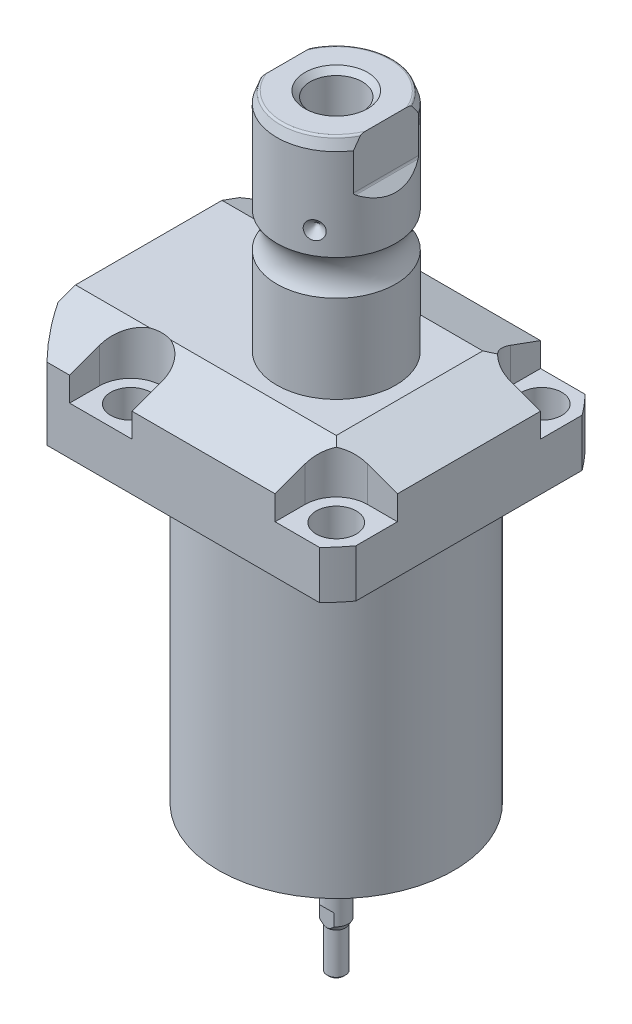
from build123d import *

# Parameters (mm, degrees)
SKETCH1_W                = 70.866
SKETCH1_H                = 85.496
EXTRUDE1_DEPTH           = 104.4448
SKETCH2_OUTSIDE_W        = 117.986
SKETCH2_OUTSIDE_H        = 103.356
SKETCH2_OUTSIDE_R        = 50.8
CUT_EXTRUDE1_DEPTH       = 105.4448
SKETCH3_W                = 45.1992
SKETCH3_H                = 79.4258
FILLET1_R                = 0.381
CUT_EXTRUDE2_DEPTH       = 12.243
CUT_EXTRUDE9_START       = -51.063
CUT_EXTRUDE9_DEPTH       = 87.496
CUT_EXTRUDE7_DEPTH       = 36.433
CUT_EXTRUDE7_DEPTH_BACK  = 36.433
SKETCH10_R               = 1.1811
SKETCH17_W               = 5.3594
SKETCH17_H               = 12.776
HOLE1_AT_2_COUNT         = 2
HOLE1_AT_2_PITCH         = 54.864
HOLE1_AT_3_COUNT         = 2
HOLE1_AT_3_PITCH         = 77.589412886
HOLE1_AT_4_COUNT         = 2
HOLE1_AT_4_PITCH         = 54.864
CHAMFER1_SIZE            = 0.635
FILLET2_R                = 0.635
CIRPATTERN1_COUNT        = 3
CUT_EXTRUDE10_DEPTH      = 36.433
CUT_EXTRUDE10_DEPTH_BACK = 36.433
CHAMFER2_SIZE            = 1.4351
SKETCH30_R               = 1.27
CUT_EXTRUDE11_DEPTH      = 7.62
SKETCH31_W               = 2.7051
SKETCH31_H               = 1.3208
CUT_EXTRUDE12_DEPTH      = 3.175


with BuildPart() as part:
    # Sketch1 → Extrude1 (new body)
    with BuildSketch(Plane(origin=(0, 0, 0), x_dir=(0, 0, 1), z_dir=(0, -1, 0))):
        with Locations((0, 7.315)):
            Rectangle(SKETCH1_W, SKETCH1_H)
    extrude(amount=-EXTRUDE1_DEPTH)

    # Sketch2 outside → Cut-Extrude1 (cut, through all)
    with BuildSketch(Plane.XZ):
        with Locations((-7.315, 0)):
            Rectangle(SKETCH2_OUTSIDE_W, SKETCH2_OUTSIDE_H)
        with Locations((-5.4102, 0)):
            Circle(SKETCH2_OUTSIDE_R, mode=Mode.SUBTRACT)
    extrude(amount=-CUT_EXTRUDE1_DEPTH, mode=Mode.SUBTRACT)

    # Sketch3 → Cut-Revolve1 (revolve, cut)
    with BuildSketch(Plane(origin=(0, 0, 0), x_dir=(0, 0, -1), z_dir=(1, 0, 0))):
        with Locations((53.9941, 39.7129)):
            Rectangle(SKETCH3_W, SKETCH3_H)
    revolve(axis=Axis((0, -93.345, 0), (0, 1, 0)), mode=Mode.SUBTRACT)

    # Fillet1
    fillet1_edges = [part.edges().sort_by_distance(p)[0] for p in [
        (0, 79.4258, 31.3945),
    ]]
    fillet(fillet1_edges, radius=FILLET1_R)

    # Sketch4 → Cut-Extrude2 (cut)
    with BuildSketch(Plane(origin=(0, 104.4448, 0), x_dir=(-1, 0, 0), z_dir=(0, 1, 0))):
        with BuildLine():
            Line((-19.1008, -35.433), (-19.1008, -27.432))
            ThreePointArc((-19.1008, -27.432), (-21.540951985, -21.540951985), (-27.432, -19.1008))
            Line((-27.432, -19.1008), (-35.433, -19.1008))
            Line((-35.433, -19.1008), (-35.433, -35.433))
            Line((-35.433, -35.433), (-19.1008, -35.433))
        make_face()
        with BuildLine():
            Line((35.7632, -35.433), (19.1008, -35.433))
            Line((19.1008, -35.433), (19.1008, -27.432))
            ThreePointArc((19.1008, -27.432), (27.432, -19.1008), (35.7632, -27.432))
            Line((35.7632, -27.432), (35.7632, -35.433))
        make_face()
        with BuildLine():
            Line((19.1008, 35.433), (19.1008, 27.432))
            ThreePointArc((19.1008, 27.432), (27.432, 19.1008), (35.7632, 27.432))
            Line((35.7632, 27.432), (35.7632, 35.433))
            Line((35.7632, 35.433), (19.1008, 35.433))
        make_face()
        with BuildLine():
            Line((-27.432, 19.1008), (-35.433, 19.1008))
            Line((-35.433, 19.1008), (-35.433, 35.433))
            Line((-35.433, 35.433), (-19.1008, 35.433))
            Line((-19.1008, 35.433), (-19.1008, 27.432))
            ThreePointArc((-19.1008, 27.432), (-21.540951985, 21.540951985), (-27.432, 19.1008))
        make_face()
    extrude(amount=-CUT_EXTRUDE2_DEPTH, mode=Mode.SUBTRACT)

    # Sketch5 → Cut-Extrude9 (cut)
    with BuildSketch(Plane(origin=(0, 0, 0), x_dir=(0, 0, -1), z_dir=(1, 0, 0)).offset(CUT_EXTRUDE9_START)):
        Polygon((-19.558, 104.4448), (-35.433, 98.666772531), (-35.433, 104.4448), align=None)
    cut_extrude9 = extrude(amount=CUT_EXTRUDE9_DEPTH, mode=Mode.SUBTRACT)

    # Mirror1: Cut-Extrude9 across plane
    add(cut_extrude9.mirror(Plane.XY), mode=Mode.SUBTRACT)

    # Sketch9 → Cut-Extrude7 (cut, two sides)
    with BuildSketch(Plane.XY) as cut_extrude7_sk:
        Polygon((19.558, 104.4448), (35.433, 98.666772531), (35.433, 104.4448), align=None)
    extrude(amount=CUT_EXTRUDE7_DEPTH, mode=Mode.SUBTRACT)
    extrude(cut_extrude7_sk.sketch, amount=-CUT_EXTRUDE7_DEPTH_BACK, mode=Mode.SUBTRACT)

    # Sketch20 → Cut-Revolve4 (revolve, cut)
    with BuildSketch(Plane(origin=(-35.0774, 88.9, -18.1102), x_dir=(0, 1, 0), z_dir=(1, 0, 0)), mode=Mode.PRIVATE) as cut_revolve4_sk:
        Polygon((-9.4742, 38.3413), (-8.0264, 38.3413), (-8.0264, 35.8902), (-7.0104, 35.8902), (-7.0104, 33.8836), (3.9624, 33.8836), (3.9624, 32.639), (-9.4742, 32.639), align=None)
    cut_revolve4 = revolve(cut_revolve4_sk.sketch.rotate(Axis((-35.0774, 81.620304954, 14.5288), (0, 1, 0)), 180), axis=Axis((-35.0774, 81.620304954, 14.5288), (0, 1, 0)), mode=Mode.SUBTRACT)  # turned: the seam where the file's is

    # Mirror10: Cut-Revolve4 across plane
    add(cut_revolve4.mirror(Plane.XY), mode=Mode.SUBTRACT)

    # Sketch15 → Revolve3 (revolve)
    with BuildSketch(Plane(origin=(0, 0, 0), x_dir=(0, 0, -1), z_dir=(1, 0, 0)), mode=Mode.PRIVATE) as revolve3_sk:
        with BuildLine():
            Line((0, 104.4448), (15.875, 104.4448))
            Line((15.875, 104.4448), (15.875, 127.82970643))
            ThreePointArc((15.875, 127.82970643), (14.3256, 132.5368), (15.875, 137.24389357))
            Line((15.875, 137.24389357), (15.875, 161.72179416))
            Line((15.875, 161.72179416), (14.81184082, 164.6428))
            Line((14.81184082, 164.6428), (0, 164.6428))
            Line((0, 164.6428), (0, 104.4448))
        make_face()
    revolve(revolve3_sk.sketch.rotate(Axis((0, 250.290824608, 0), (0, -1, 0)), 180), axis=Axis((0, 250.290824608, 0), (0, -1, 0)))  # turned: the seam where the file's is

    # Sketch17 → Hole1 (revolve, cut)
    with BuildSketch(Plane(origin=(27.432, 92.2018, -27.432), x_dir=(0, 0, 1), z_dir=(1, 0, 0))):
        with Locations((2.6797, 6.388)):
            Rectangle(SKETCH17_W, SKETCH17_H)
    hole1 = revolve(axis=Axis((27.432, -17.7982, -27.432), (0, 1, 0)), mode=Mode.SUBTRACT)

    # Hole1 at 2: Hole1 ×2
    with Locations(*[(0, 0, i * HOLE1_AT_2_PITCH) for i in range(1, HOLE1_AT_2_COUNT)]):
        add(hole1, mode=Mode.SUBTRACT)

    # Hole1 at 3: Hole1 ×2
    with Locations(*[Vector(-0.707106781, 0, 0.707106781) * (i * HOLE1_AT_3_PITCH) for i in range(1, HOLE1_AT_3_COUNT)]):
        add(hole1, mode=Mode.SUBTRACT)

    # Hole1 at 4: Hole1 ×2
    with Locations(*[(-i * HOLE1_AT_4_PITCH, 0, 0) for i in range(1, HOLE1_AT_4_COUNT)]):
        add(hole1, mode=Mode.SUBTRACT)

    # Chamfer1
    chamfer1_edges = [part.edges().sort_by_distance(p)[0] for p in [
        (-35.0774, 81.8896, 15.7734),
        (-35.0774, 81.8896, -15.7734),
    ]]
    chamfer(chamfer1_edges, length=CHAMFER1_SIZE)

    # Sketch21 → Cut-Revolve5 (revolve, cut)
    with BuildSketch(Plane.XZ.offset(-91.9226)):
        Polygon((-50.063, -1.9304), (-49.809, -1.9304), (-49.809, -6.7564), (-47.2563, -7.440393904), (-46.695693904, -8.001), (-30.759, -8.001), (-30.759, -12.9794), (-50.063, -12.9794), align=None)
    cut_revolve5 = revolve(axis=Axis((-57.549532301, 91.9226, -12.9794), (1, 0, 0)), mode=Mode.SUBTRACT)

    # Mirror13: Cut-Revolve5 across plane
    add(cut_revolve5.mirror(Plane.XY), mode=Mode.SUBTRACT)

    # Fillet2
    fillet2_edges = [part.edges().sort_by_distance(p)[0] for p in [
        (0, 164.6428, -14.81184082),
    ]]
    fillet(fillet2_edges, radius=FILLET2_R)

    # Sketch26 → Cut-Revolve7 (revolve, cut)
    with BuildSketch(Plane.XY, mode=Mode.PRIVATE) as cut_revolve7_sk:
        Polygon((-15.875, 145.6178), (-13.462, 143.2048), (-15.875, 143.2048), align=None)
    cut_revolve7 = revolve(cut_revolve7_sk.sketch.rotate(Axis((-39.772000707, 143.2048, 0), (1, 0, 0)), 90), axis=Axis((-39.772000707, 143.2048, 0), (1, 0, 0)), mode=Mode.SUBTRACT)  # turned: the seam where the file's is

    # CirPattern1: Cut-Revolve7 ×3 about axis
    cirpattern1_axis = Axis((0, 250.290824608, 0), (0, 1, 0))
    for i in range(1, CIRPATTERN1_COUNT):
        add(cut_revolve7.rotate(cirpattern1_axis, i * 360 / CIRPATTERN1_COUNT), mode=Mode.SUBTRACT)

    # Sketch27 → Hole2 (revolve, cut)
    with BuildSketch(Plane(origin=(0, 164.6428, 0), x_dir=(0, 0, 1), z_dir=(1, 0, 0))):
        Polygon((0, 0), (0, 28.812118634), (6.9469, 24.638), (6.9469, 0), align=None)
    revolve(axis=Axis((0, 168.886999587, 0), (0, -1, 0)), mode=Mode.SUBTRACT)

    # Sketch29 → Cut-Extrude10 (cut, two sides)
    with BuildSketch(Plane.XY) as cut_extrude10_sk:
        with BuildLine():
            Line((13.284, 164.6428), (13.284, 151.9428))
            ThreePointArc((13.284, 151.9428), (13.342003912, 151.651194643), (13.507185078, 151.403983558))
            Line((13.507185078, 151.403983558), (16.332, 148.579168636))
            Line((16.332, 148.579168636), (16.332, 164.6428))
            Line((16.332, 164.6428), (13.284, 164.6428))
        make_face()
        with BuildLine():
            Line((-16.332, 164.6428), (-13.284, 164.6428))
            Line((-13.284, 164.6428), (-13.284, 151.9428))
            ThreePointArc((-13.284, 151.9428), (-13.342003912, 151.651194643), (-13.507185078, 151.403983558))
            Line((-13.507185078, 151.403983558), (-16.332, 148.579168636))
            Line((-16.332, 148.579168636), (-16.332, 164.6428))
        make_face()
    extrude(amount=CUT_EXTRUDE10_DEPTH, mode=Mode.SUBTRACT)
    extrude(cut_extrude10_sk.sketch, amount=-CUT_EXTRUDE10_DEPTH_BACK, mode=Mode.SUBTRACT)

    # Chamfer2
    chamfer2_edges = [part.edges().sort_by_distance(p)[0] for p in [
        (0, 164.6428, -6.9469),
    ]]
    chamfer(chamfer2_edges, length=CHAMFER2_SIZE)

    # Sketch30 → Cut-Extrude11 (cut)
    with BuildSketch(Plane.XZ):
        with Locations(Location((19.431, 0, 0), (0, 0, 270))):  # turned: the seam where the file's is
            Circle(SKETCH30_R)
        with Locations(Location((18.768904731, -5.029112865, 0), (0, 0, 270))):  # turned: the seam where the file's is
            Circle(SKETCH30_R)
        with Locations(Location((-9.7155, -16.827739621, 0), (0, 0, 270))):  # turned: the seam where the file's is
            Circle(SKETCH30_R)
        with Locations(Location((-13.739791865, -13.739791865, 0), (0, 0, 270))):  # turned: the seam where the file's is
            Circle(SKETCH30_R)
        with Locations(Location((-9.7155, 16.827739621, 0), (0, 0, 270))):  # turned: the seam where the file's is
            Circle(SKETCH30_R)
        with Locations(Location((-5.029112865, 18.768904731, 0), (0, 0, 270))):  # turned: the seam where the file's is
            Circle(SKETCH30_R)
    extrude(amount=-CUT_EXTRUDE11_DEPTH, mode=Mode.SUBTRACT)

    # Sketch31 → Cut-Revolve8 (revolve, cut)
    with BuildSketch(Plane(origin=(0, 0, 0), x_dir=(0, 0, -1), z_dir=(1, 0, 0)), mode=Mode.PRIVATE) as cut_revolve8_sk:
        with Locations((12.99845, 0.6604)):
            Rectangle(SKETCH31_W, SKETCH31_H)
    revolve(cut_revolve8_sk.sketch.rotate(Axis((0, 61.617584575, 0), (0, -1, 0)), 180), axis=Axis((0, 61.617584575, 0), (0, -1, 0)), mode=Mode.SUBTRACT)  # turned: the seam where the file's is

    # Sketch32 → Revolve5 (revolve)
    with BuildSketch(Plane(origin=(0, 0, 0), x_dir=(0, 0, -1), z_dir=(1, 0, 0)), mode=Mode.PRIVATE) as revolve5_sk:
        Polygon((3.175, 0), (3.175, -26.486371375), (2.4384, -27.7622), (2.4384, -38.6842), (1.9304, -39.1922), (0, -39.1922), (0, 0), align=None)
    revolve(revolve5_sk.sketch.rotate(Axis((0, 46.642918558, 0), (0, -1, 0)), 180), axis=Axis((0, 46.642918558, 0), (0, -1, 0)))  # turned: the seam where the file's is

    # Sketch33 → Cut-Extrude12 (cut, symmetric)
    with BuildSketch(Plane(origin=(0, 0, 0), x_dir=(0, 0, -1), z_dir=(1, 0, 0))):
        Polygon((2.5019, -27.652214774), (2.5019, -23.3172), (3.2639, -22.5552), (3.2639, -27.652214774), align=None)
    cut_extrude12 = extrude(amount=CUT_EXTRUDE12_DEPTH, both=True, mode=Mode.SUBTRACT)

    # Mirror14: Cut-Extrude12 across plane
    add(cut_extrude12.mirror(Plane.XY), mode=Mode.SUBTRACT)


with BuildPart() as body_2:
    # Sketch10 → Revolve4 (revolve)
    with BuildSketch(Plane(origin=(-35.0774, 88.9, -18.1102), x_dir=(0, 1, 0), z_dir=(1, 0, 0))):
        with Locations((-9.2075, 8.1026)):
            Circle(SKETCH10_R)
    revolve(axis=Axis((-35.0774, 87.86749, -14.5288), (0, 1, 0)))


with BuildPart() as body_3:
    # Mirror12: mirrored copy
    add(body_2.part.mirror(Plane.XY))


solid = Compound([part.part, body_2.part, body_3.part])
